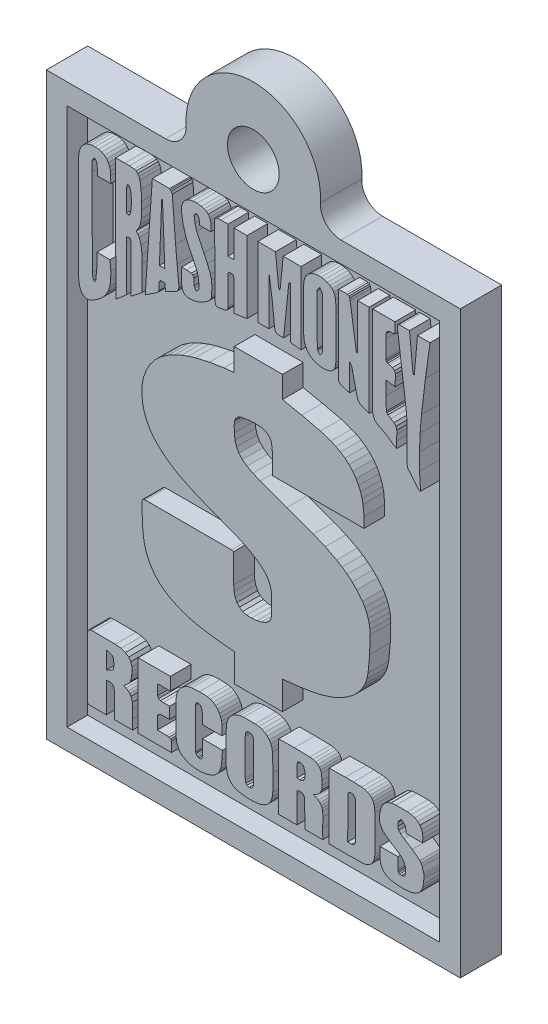
from build123d import *

# Parameters (mm, degrees)
SKETCH3_W           = 63.5
SKETCH3_H           = 88.9
BOSS_EXTRUDE1_DEPTH = 6.35
SKETCH4_W           = 57.15
SKETCH4_H           = 82.55
CUT_EXTRUDE1_DEPTH  = 3.175
BOSS_EXTRUDE2_DEPTH = 3.175
SKETCH6_R           = 3.96875
BOSS_EXTRUDE4_DEPTH = 6.35


with BuildPart() as part:
    # Sketch3 → Boss-Extrude1 (new body)
    with BuildSketch(Plane.XY):
        with Locations((31.75, 44.45)):
            Rectangle(SKETCH3_W, SKETCH3_H)
    extrude(amount=BOSS_EXTRUDE1_DEPTH)

    # Sketch4 → Cut-Extrude1 (cut)
    with BuildSketch(Plane.XY.offset(6.35)):
        with Locations((31.75, 44.45)):
            Rectangle(SKETCH4_W, SKETCH4_H)
    extrude(amount=-CUT_EXTRUDE1_DEPTH, mode=Mode.SUBTRACT)

    # Sketch5 → Boss-Extrude2 (add)
    with BuildSketch(Plane.XY.offset(3.175)):
        Polygon((36.242313877, 26.0782335), (36.218686822, 21.742658016), (28.835213285, 21.74253872), (28.835213285, 26.030896929), (26.804749115, 26.236158537), (24.854026883, 26.467999959), (23.270449094, 26.731960427), (21.718991193, 27.108889057), (20.214052769, 27.640870343), (18.770030909, 28.369989608), (17.985787151, 28.892464651), (17.289453332, 29.475299945), (16.680336685, 30.116834935), (16.157745692, 30.815408642), (15.720988005, 31.569359255), (15.369371261, 32.377026213), (15.102203535, 33.236748123), (14.918792471, 34.146864005), (14.793457399, 35.288723359), (14.731251573, 36.441659517), (14.658893193, 38.754189969), (14.675875085, 39.015935245), (14.768168948, 39.200153774), (14.944634303, 39.309060332), (15.214131496, 39.344870534), (28.409936339, 39.333057006), (28.740717622, 39.262175422), (28.740717622, 34.84388599), (28.794709404, 34.008095871), (28.957792758, 33.307562313), (29.23162825, 32.741316271), (29.617878111, 32.308389124), (30.118202893, 32.007810991), (30.734264413, 31.838613246), (31.467724069, 31.79982727), (32.32024325, 31.890483179), (32.987712161, 32.047013468), (33.619739651, 32.292146046), (34.021217496, 32.544662187), (34.315266419, 32.876920681), (34.491916789, 33.288920699), (34.541200657, 33.780662234), (34.520526773, 34.784820028), (34.553014185, 35.788974472), (34.565243375, 36.457436282), (34.4825018, 37.074259223), (34.311712147, 37.64318133), (34.059796272, 38.167941053), (33.73367644, 38.652276005), (33.340274083, 39.099924228), (32.379311726, 39.900113024), (30.940450278, 40.764352808), (29.427386128, 41.471323903), (26.30712007, 42.68812561), (24.35695373, 43.443089217), (22.427829632, 44.235709017), (20.554076162, 45.143510503), (19.648690797, 45.664831904), (18.770020863, 46.244021672), (18.044637539, 46.788070572), (17.370477423, 47.369082896), (16.754461948, 47.991904692), (16.20351338, 48.661380335), (15.724554415, 49.382355039), (15.3245069, 50.159674433), (15.010293104, 50.998183313), (14.788834461, 51.902727307), (14.647232451, 53.170798267), (14.697093978, 54.405365892), (14.932742916, 55.592863587), (15.34850357, 56.719724339), (15.93869982, 57.772381973), (16.69765513, 58.737269897), (17.619694212, 59.600821512), (18.699140533, 60.349470645), (19.699905213, 60.894280547), (20.724618844, 61.356580356), (21.77065183, 61.745783388), (22.835374146, 62.071303794), (25.010366711, 62.568952092), (27.228555959, 62.924838064), (28.823394732, 63.102042233), (28.823394732, 66.563428401), (36.230520858, 66.563428401), (36.230520858, 63.220177508), (39.185398373, 62.613253451), (42.042808211, 61.944306489), (43.640047198, 61.414724578), (44.397480921, 61.078982971), (45.118781706, 60.684680641), (45.797442954, 60.223372478), (46.426957629, 59.686614629), (47.000818711, 59.065961144), (47.512519173, 58.352968169), (47.901053713, 57.653173428), (48.204169773, 56.936627435), (48.43058958, 56.204299237), (48.58903451, 55.457157459), (48.736888203, 53.922310574), (48.717505679, 52.339839965), (34.659315839, 52.339839965), (34.659315839, 55.600397841), (34.558715837, 56.553792878), (34.424451342, 56.931712738), (34.226642777, 57.246919017), (33.959613606, 57.501765461), (33.617687707, 57.698604567), (33.195188964, 57.839790912), (32.686441674, 57.927677829), (31.995160693, 57.96404141), (31.293912177, 57.926201033), (29.910241778, 57.703219134), (29.441389736, 57.510324848), (29.101010119, 57.178989769), (28.893533734, 56.734686942), (28.823390546, 56.202890253), (28.832135369, 55.074759491), (28.942080459, 54.172979464), (29.172469362, 53.402718382), (29.542544372, 52.740026872), (30.071549882, 52.160953892), (30.778728185, 51.641550065), (31.68332283, 51.157864766), (32.804576949, 50.685948204), (36.886183776, 49.193004142), (40.967765487, 47.708920016), (42.784475636, 46.952478777), (44.523657364, 46.060920369), (45.352408845, 45.545782421), (46.147659081, 44.9744375), (46.904701421, 44.339409956), (47.618829201, 43.633223719), (48.494696656, 42.527175404), (48.847974375, 41.941202335), (49.141307083, 41.332526048), (49.372064767, 40.700591906), (49.537616983, 40.044847783), (49.635333301, 39.364739042), (49.662583696, 38.659712726), (49.593178908, 36.040044373), (49.355429885, 33.438101749), (49.177810473, 32.578108174), (48.898021755, 31.78567381), (48.523539378, 31.057475447), (48.061839414, 30.390191557), (47.520397929, 29.780499344), (46.906689735, 29.22507644), (46.228191743, 28.720600889), (45.49237876, 28.263749906), (44.719740489, 27.862224758), (43.927443006, 27.521337388), (42.293839603, 26.99378565), (40.611505713, 26.625718628), (38.900378498, 26.361760253), align=None)
        Polygon((9.870694513, 79.806407401), (9.882500925, 78.731234913), (7.815112679, 78.731234913), (7.825449409, 79.556710903), (7.791485622, 80.337886376), (7.634955336, 80.643563388), (7.389822757, 80.940379627), (7.177177588, 80.655376078), (7.03541442, 80.361511755), (7.011786948, 78.849370188), (7.059041474, 65.499983627), (7.125493091, 65.02743834), (7.236245643, 64.554893053), (7.567012695, 64.555169326), (7.744216863, 66.504413923), (7.756030389, 68.559981107), (9.764374021, 68.559847158), (9.886434441, 67.13473732), (9.8746544, 65.953633631), (9.732317762, 64.979140678), (9.462707544, 64.17386221), (9.069107198, 63.500402399), (8.554798901, 62.921365837), (7.923066937, 62.399356688), (7.177193912, 61.896979126), (6.505848415, 61.602377661), (6.207208784, 61.573028021), (5.935287938, 61.622312727), (5.691609131, 61.75023219), (5.477695205, 61.95678516), (5.295068585, 62.241972889), (5.14525211, 62.605794963), (5.002012146, 63.209765846), (4.956234412, 63.822598344), (4.956234412, 79.794594711), (4.999935506, 80.385528939), (5.128639416, 80.907104845), (5.338746655, 81.356414461), (5.626657334, 81.730550661), (5.988772384, 82.026606316), (6.421491909, 82.241673882), (6.921216429, 82.37284665), (7.484346884, 82.417217075), (8.013767637, 82.372385362), (8.483520491, 82.240197507), (8.89042079, 82.024114433), (9.231284301, 81.727597487), (9.502928039, 81.354107176), (9.702166938, 80.907104845), (9.825817171, 80.390050999), align=None)
        Polygon((10.671410737, 63.769604488), (10.594066917, 82.50484949), (12.051091109, 82.552967994), (12.769270029, 82.547586564), (13.481449261, 82.464328445), (13.766587177, 82.354913716), (14.005054505, 82.147441516), (14.199517256, 81.8407243), (14.352643125, 81.433575356), (14.545550387, 80.31323335), (14.605111546, 78.776918879), (14.605111546, 77.601811532), (14.577219866, 76.497614235), (14.424649889, 75.621348279), (14.156068993, 74.935025111), (13.780144564, 74.40065617), (14.035099004, 74.129593437), (14.242298699, 73.789676787), (14.52776898, 72.91657623), (14.665226084, 71.807946453), (14.683338179, 70.490379398), (14.676226287, 66.651548054), (13.012072723, 65.336643253), (13.012068537, 68.808909906), (12.990733276, 72.354496025), (12.94739552, 72.777116159), (12.846719753, 72.954712132), (12.700706194, 72.984154277), (12.521356738, 72.96231378), (12.359786175, 72.908496131), (12.295558124, 72.774903478), (12.29378036, 72.253196554), (12.29378036, 65.161856877), align=None)
        Polygon((12.307992425, 79.30388333), (12.300880532, 76.021684206), (12.526678728, 75.921964085), (12.72047508, 75.983695231), (12.876935043, 76.246764934), (12.990724487, 76.751060487), (13.04795157, 77.577942532), (13.027171365, 78.473203393), (12.94371902, 79.246901121), (12.812928428, 79.709092933), (12.636023552, 79.905050062), (12.475119391, 79.893969908), (12.356886163, 79.689149078), align=None, mode=Mode.SUBTRACT)
        Polygon((18.913367148, 68.931172505), (18.288724474, 68.573809739), (18.182401889, 69.672743233), (17.438143795, 69.672466964), (17.33154452, 69.441017347), (17.294165432, 69.194200768), (17.314100919, 68.681601167), (17.272015174, 68.188937052), (17.15710976, 67.967040144), (16.941973126, 67.770477311), (15.169931441, 66.600928878), (16.256782669, 82.596575741), (18.891217726, 82.572948687), (19.02578235, 82.511480836), (19.161454155, 82.373593839), (19.316508065, 82.041335763), (19.824491421, 75.650176352), (20.059286852, 73.104342753), (20.320662091, 70.558496597), (20.317708499, 70.087059326), (20.199572806, 69.702009991), (19.935243558, 69.40556295), align=None)
        Polygon((18.170681289, 71.574552891), (17.816179187, 80.564880909), (17.698089958, 80.564671613), (17.34368162, 71.574511032), align=None, mode=Mode.SUBTRACT)
        Polygon((25.260839696, 81.091125378), (25.223552283, 80.009624185), (23.510578233, 80.009617489), (23.497287911, 80.476255592), (23.439696649, 80.907453112), (23.268399246, 81.146678928), (23.026220256, 81.368185709), (22.791424828, 81.128959893), (22.671811918, 80.907453112), (22.804715149, 79.922493245), (23.061661257, 78.981833895), (24.158851314, 76.679655664), (24.701353513, 75.528013376), (25.176296079, 74.350899294), (25.335410758, 73.674939647), (25.385987657, 72.956894258), (25.365313776, 71.492006381), (25.326735001, 71.269762875), (25.225027404, 71.043088984), (24.916398054, 70.665055267), (24.214410724, 70.156700616), (23.455940147, 69.779034005), (22.642092665, 69.551990498), (21.773975456, 69.495506833), (21.369174817, 69.596660634), (21.051869295, 69.852867924), (20.838670747, 70.246409672), (20.746191865, 70.759565162), (20.722564811, 71.871521497), (20.734378336, 73.063219771), (21.514076178, 73.073556504), (22.258332597, 73.039592717), (22.487221262, 72.877155666), (22.636367989, 72.590676995), (22.671808572, 71.562893404), (22.804711803, 71.274936266), (22.990775908, 70.995838222), (23.271348652, 71.266074236), (23.386161972, 71.399531266), (23.427878938, 71.527451146), (23.364380912, 72.629069495), (23.283346778, 73.168804378), (23.132538655, 73.677528226), (22.73069119, 74.593082469), (22.28343519, 75.490916839), (21.838394803, 76.38875163), (21.443194176, 77.304308801), (21.000183545, 78.806114475), (20.734378336, 80.352221505), (20.724826048, 81.000217056), (20.855098841, 81.551303341), (21.111075488, 82.002712617), (21.478635595, 82.351675062), (21.943658349, 82.595422935), (22.492022523, 82.731186832), (23.109606884, 82.756198171), (23.782291043, 82.667688807), (24.215380602, 82.547175924), (24.569004916, 82.376963513), (24.84676346, 82.151651304), (25.052255713, 81.865840289), (25.189081578, 81.514131456), align=None)
        Polygon((27.868589875, 78.082840022), (28.778238191, 78.082840022), (28.778242798, 82.288478844), (30.786555032, 82.288478844), (30.786555032, 71.254580514), (28.76642592, 70.947426703), (28.76642592, 75.42478796), (28.730984919, 75.873704515), (28.596973672, 76.022851242), (28.305693325, 76.074536159), (28.013121616, 76.00586935), (27.887786963, 75.844170698), (27.868590293, 75.401158392), (27.880403822, 71.396342425), (27.854561572, 71.1026627), (27.753407353, 70.898693288), (27.568081647, 70.763391099), (27.28972326, 70.675713896), (26.462032075, 70.524721175), (26.211546529, 70.524121331), (26.046340908, 70.593018786), (25.948694077, 70.746088147), (25.900886169, 70.998004023), (25.883904277, 71.857075019), (25.813022693, 81.390652843), (25.823175243, 81.937033306), (25.929682008, 82.217606885), (26.220038525, 82.320976299), (26.781738647, 82.335743417), (27.868589875, 82.335743417), align=None)
        Polygon((39.065997273, 82.312102131), (39.065997273, 71.230944667), (37.423905646, 71.408092324), (37.423905646, 79.264159286), (37.211260476, 79.275972815), (36.396122052, 71.490815482), (35.746373853, 71.490815482), (35.409316608, 71.512227762), (35.194087048, 71.644392597), (35.071889327, 71.882880434), (35.013928448, 72.223260887), (34.647706167, 75.689081628), (34.13972239, 79.146033222), (34.13972239, 71.573521059), (32.438561032, 71.573521059), (32.438561032, 82.323906449), (35.155693291, 82.323906449), (35.66367665, 77.574844945), (35.852694345, 77.574844945), (36.337052321, 82.312102131), align=None)
        Polygon((44.403894181, 78.790327664), (44.403895438, 72.221977898), (44.373899909, 71.839673699), (44.285759324, 71.500424701), (44.14224267, 71.20630713), (43.946118107, 70.959398459), (43.700155039, 70.761774076), (43.407122042, 70.615511872), (42.690921387, 70.485378471), (41.97285172, 70.526818325), (41.336601047, 70.675134983), (40.786460365, 70.926451015), (40.326721509, 71.276891092), (39.961676309, 71.722578207), (39.695616177, 72.259636188), (39.53283337, 72.884188447), (39.477618462, 73.592358812), (39.477618462, 80.160708578), (39.521504156, 80.628384374), (39.640425129, 81.053558764), (39.828566292, 81.431386534), (40.080113806, 81.757022472), (40.389252164, 82.025620531), (40.750167526, 82.232335075), (41.157044804, 82.372321318), (41.604070159, 82.440733622), (42.150703449, 82.440156799), (42.652343454, 82.369667437), (43.102760664, 82.232449771), (43.495724754, 82.031687614), (43.825006217, 81.770565206), (44.084374302, 81.4522672), (44.267600348, 81.079976994), (44.36845318, 80.656879244), (44.412754118, 79.728034679), align=None)
        Polygon((42.388196292, 74.519727838), (42.383765904, 76.38037098), (42.36013885, 80.243422108), (42.308453936, 80.427456036), (42.19474821, 80.608167175), (41.923035821, 80.964050634), (41.657229359, 80.597828352), (41.544261612, 80.415824598), (41.497745481, 80.231605229), (41.568627065, 72.647246889), (41.619388565, 72.472072897), (41.744354438, 72.300221274), (42.018439702, 71.999907573), (42.21985206, 72.31058396), (42.348325325, 72.659084695), align=None, mode=Mode.SUBTRACT)
        Polygon((49.528407523, 82.133879107), (49.516593994, 68.004779638), (48.754611005, 68.297179721), (48.098956879, 68.607286285), (47.844964363, 68.887859447), (47.697294012, 69.257034484), (46.882155591, 72.812930547), (46.771403039, 73.099410472), (46.527747253, 73.368168851), (46.527747253, 69.245217609), (45.756908513, 69.4711531), (45.110115581, 69.705950203), (44.893040441, 69.925978935), (44.791148244, 70.225750438), (44.791148244, 81.968493907), (44.873843353, 82.192952605), (45.913439637, 82.192952605), (46.206565981, 82.169878929), (46.406659225, 82.06152617), (46.531440498, 81.862355505), (46.598630094, 81.566829786), (47.543720668, 75.305601597), (47.588021606, 75.183035516), (47.756365838, 75.069329373), (47.756365838, 82.133879107), align=None)
        Polygon((50.053551093, 81.283113828), (50.06536504, 82.169136765), (53.479499191, 82.169138022), (53.479499191, 80.574299248), (53.243226967, 80.503417665), (52.594400926, 80.444349606), (52.261220271, 80.296679258), (52.138469172, 79.945224512), (52.120933478, 79.274801591), (52.109119953, 76.652179227), (52.124809649, 76.411661215), (52.199198624, 76.225412512), (52.346684793, 76.098970261), (52.58166524, 76.037873286), (53.096664213, 75.912722812), (53.41452437, 75.648024365), (53.555180779, 75.250422688), (53.538568503, 74.726564195), (53.514941028, 74.172800594), (53.526754975, 73.557015761), (52.120935992, 73.746033459), (52.112075637, 71.663885628), (52.156376575, 69.634894904), (52.230396348, 69.450307176), (52.40298595, 69.265719449), (52.853379722, 68.985146705), (53.326108352, 68.707157516), (53.622740409, 68.347211196), (53.762104202, 67.898663839), (53.763028038, 67.354869863), (53.734970596, 66.454082319), (53.751214509, 65.4646929), (53.219601585, 65.760033183), (52.278942234, 66.42011895), (51.799198825, 66.725242163), (51.293982367, 66.965019685), (50.91986877, 67.138970551), (50.624667044, 67.342132919), (50.399792684, 67.574921194), (50.236663281, 67.837751461), (50.061304689, 68.455197688), (50.029924039, 69.197793967), (50.063888244, 75.240449292), align=None)
        Polygon((54.305524794, 82.127336499), (55.711343777, 82.115522973), (56.254769812, 76.598588042), (56.443787506, 76.586774513), (56.939958176, 82.080094111), (58.865577393, 82.080094111), (58.155100161, 76.975877498), (57.549837079, 71.876087509), (57.345844224, 69.322314042), (57.239175462, 66.763001752), (57.253504316, 64.195935032), (57.412503463, 61.618898683), (57.188044765, 61.618898683), (55.486883407, 63.639027796), (55.377607648, 63.937321667), (55.356933768, 64.288775995), (55.334783088, 65.913146495), (55.356933768, 67.537516992), (55.36265593, 69.161702892), (55.260948333, 70.775920839), (54.872575791, 73.987739855), (53.844792197, 81.572098195), (53.838700833, 81.819999347), (53.902383877, 81.995911739), (54.052454019, 82.098726936), align=None)
        Polygon((51.198253531, 9.834410886), (51.174626474, 11.334739767), (53.939017869, 11.334729721), (53.939017869, 9.739890948), (53.957107359, 9.488851604), (54.030573334, 9.282113615), (54.188211635, 9.141827243), (54.458818101, 9.090142746), (54.736437674, 9.12835232), (54.925455368, 9.254056593), (55.043591482, 9.457288028), (55.108566303, 9.728078255), (55.118349655, 10.456276616), (54.912165047, 11.061539279), (54.508840786, 11.56712452), (53.927205177, 11.99629061), (52.813772463, 12.681480649), (51.788940789, 13.472994108), (51.485270512, 13.811435638), (51.275601956, 14.1759036), (51.148721019, 14.560307046), (51.093414439, 14.95855503), (51.152667095, 15.772217912), (51.36365045, 16.568161759), (51.509105606, 16.91310948), (51.703291249, 17.212371976), (52.22013622, 17.672732861), (52.878744356, 17.947030062), (53.643675494, 18.033048379), (55.368462232, 18.033048379), (55.990799716, 17.966181522), (56.5261963, 17.803790098), (56.970776235, 17.550028225), (57.320662098, 17.209048346), (57.57197813, 16.785004579), (57.720847748, 16.282049776), (57.763394782, 15.704337222), (57.695742223, 15.056020192), (55.167629755, 15.056020192), (55.160246193, 15.52856464), (55.073120695, 15.965668508), (54.799930674, 16.272822734), (54.446997876, 16.54453638), (54.150180383, 16.246242923), (54.020046143, 16.092666648), (53.950827209, 15.930230436), (53.918708999, 15.348409811), (54.04828944, 14.917212705), (54.359504016, 14.561327993), (54.872288215, 14.205443698), (56.12305413, 13.419839512), (57.294078102, 12.527911905), (57.511152821, 12.248446341), (57.66620631, 11.89588358), (57.896571354, 11.122092923), (57.929058763, 10.752918304), (57.908384882, 10.366022139), (57.871213419, 9.712627576), (57.757207143, 9.150327191), (57.562628439, 8.676075302), (57.283739277, 8.286825807), (56.916801617, 7.979533443), (56.45807785, 7.751152532), (55.903829935, 7.598637388), (55.250320261, 7.518941913), (54.117690878, 7.521895087), (52.993920596, 7.648891552), (52.591150552, 7.749584064), (52.234896641, 7.907314037), (51.92737405, 8.11820572), (51.670797144, 8.37838211), (51.467381945, 8.683967033), (51.319342816, 9.031084319), (51.228894946, 9.415857799), align=None)
        Polygon((43.377518317, 7.755212044), (43.377518317, 17.83220711), (45.883468807, 17.86322233), (47.127040363, 17.857130966), (48.362862931, 17.796770713), (48.870755454, 17.721413117), (49.298353076, 17.583756345), (49.649531131, 17.383524965), (49.928166209, 17.120441032), (50.138134895, 16.794228689), (50.283313364, 16.404609996), (50.36757778, 15.951309098), (50.394804733, 15.434048466), (50.394804733, 9.834406283), (50.362594011, 9.41562255), (50.267808265, 9.031449332), (50.113216063, 8.687701298), (49.90158598, 8.390192707), (49.635687428, 8.144737393), (49.31828856, 7.957150865), (48.952158368, 7.833246544), (48.540065843, 7.778839098), (45.98094234, 7.740444926), align=None)
        Polygon((46.248211366, 15.882942839), (46.236397838, 9.444524295), (46.825418677, 9.430687707), (47.200685917, 9.564144737), (47.400963341, 9.868160355), (47.465014744, 10.365992837), (47.465014744, 15.268636059), (47.430312143, 15.634489142), (47.311437633, 15.936104967), (47.086240117, 16.149118499), (46.732569343, 16.249164702), (46.432799094, 16.119215063), align=None, mode=Mode.SUBTRACT)
        Polygon((35.628088304, 7.814261682), (35.628088304, 17.843997615), (38.04840851, 17.872073474), (40.424416895, 17.820388978), (40.898069359, 17.756590405), (41.29419508, 17.635616232), (41.617223603, 17.45677369), (41.871585735, 17.219370848), (42.061710609, 16.922715349), (42.192029449, 16.566115258), (42.290968475, 15.670311901), (42.290968475, 14.985121444), (42.244636943, 14.341279172), (41.991197808, 13.830340128), (41.545048567, 13.43015406), (40.920587562, 13.118569864), (41.344100555, 12.960516317), (41.688287274, 12.762315532), (41.959100526, 12.525904753), (42.1624927, 12.253222904), (42.304417863, 11.946207648), (42.390827985, 11.606797495), (42.42091644, 10.83854482), (42.392858998, 9.354459856), (42.409102911, 7.826074371), (39.644719893, 7.826074371), (39.644719893, 9.858016177), (39.609278892, 11.925396048), (39.537289711, 12.208737365), (39.370053076, 12.393509275), (39.12750447, 12.491894921), (38.82957854, 12.516076613), (38.561188523, 12.447779002), (38.454496737, 12.28866474), (38.451543148, 11.866328411), (38.451543148, 7.814261682), align=None)
        Polygon((38.475174388, 15.977466966), (38.46336086, 14.063660438), (38.83844643, 14.005517052), (39.160367356, 14.041511852), (39.420266637, 14.194903948), (39.609282657, 14.488952453), (39.704345515, 14.971096491), (39.669827511, 15.493110661), (39.531202115, 15.944242414), (39.313942378, 16.21373919), (39.020078891, 16.327999132), (38.752796054, 16.321538571), (38.55639438, 16.202110262), align=None, mode=Mode.SUBTRACT)
        Polygon((27.583072714, 10.33057737), (27.59488624, 12.870502529), (27.583067272, 14.181816223), (27.606694326, 15.493127406), (27.683113892, 16.031569673), (27.845920142, 16.517958662), (28.088468748, 16.946755971), (28.40411413, 17.312424039), (28.78621113, 17.609425715), (29.228114163, 17.832222599), (29.723178492, 17.975277544), (30.264758948, 18.033052568), (32.060426015, 18.033052568), (32.580132903, 17.975046063), (33.061630217, 17.839235284), (33.496610979, 17.62977477), (33.876769056, 17.350816539), (34.193798308, 17.006514289), (34.439392178, 16.601021298), (34.605244106, 16.138490427), (34.683048379, 15.623075371), (34.777557438, 12.935479025), (34.730302908, 10.247882676), (34.670888676, 9.707894966), (34.545161382, 9.230620833), (34.352151985, 8.815644623), (34.090891021, 8.462551505), (33.76040987, 8.170926235), (33.35973949, 7.940353152), (32.88791125, 7.77041701), (32.343955279, 7.66070257), (31.617233297, 7.592959175), (30.88054378, 7.597204544), (29.425994726, 7.790652209), (29.016832771, 7.913356842), (28.657924977, 8.101128807), (28.349686595, 8.349261022), (28.092533284, 8.653045995), (27.886879872, 9.007777486), (27.73314202, 9.408747999), align=None)
        Polygon((31.776899679, 10.011607941), (31.776899679, 15.587637302), (31.763978556, 15.906973837), (31.691251396, 16.184224208), (31.507771684, 16.381732641), (31.162593738, 16.46184336), (30.816860737, 16.398898716), (30.620644081, 16.215233985), (30.532965203, 15.945181736), (30.512845539, 15.623075371), (30.512845539, 10.035237506), (30.529089035, 9.709072047), (30.607354178, 9.428313867), (30.791941487, 9.229511981), (31.12715148, 9.149214572), (31.467901134, 9.21418939), (31.664671167, 9.403207088), (31.755118619, 9.680827075), align=None, mode=Mode.SUBTRACT)
        Polygon((26.944896931, 15.363166464), (26.933083406, 13.886467151), (23.932427739, 13.886471758), (23.94719486, 14.843374601), (23.908800685, 15.764836028), (23.737503279, 16.156161741), (23.586510558, 16.321367784), (23.424442708, 16.414584227), (23.170080574, 16.415138026), (23.002105961, 16.286111384), (22.909443317, 16.070697641), (22.881017094, 15.812090975), (22.904644149, 9.728095001), (22.952267877, 9.559566586), (23.072987963, 9.381069804), (23.233579017, 9.231368861), (23.400814815, 9.149227129), (23.660160298, 9.151995702), (23.827581115, 9.277699972), (23.917475185, 9.489790925), (23.944240429, 9.75172038), (23.944240429, 12.008120045), (27.015778515, 12.008120045), (26.92717664, 10.698286076), (26.859617428, 10.056105197), (26.732251761, 9.432752626), (26.595610497, 9.057554876), (26.409961217, 8.72818132), (25.908251311, 8.199707006), (25.260348267, 7.832931341), (24.499477479, 7.613455993), (23.759466011, 7.51359397), (23.027206461, 7.505656612), (22.301592074, 7.601827065), (21.581516926, 7.814287216), (20.849257379, 8.22148723), (20.563769517, 8.481709244), (20.330750597, 8.777095989), (20.018243822, 9.465607979), (19.903985136, 10.271519358), (19.903985136, 15.245030351), (19.956615654, 15.750870094), (20.092449453, 16.226114468), (20.304979091, 16.662317942), (20.587697958, 17.051036662), (20.934099872, 17.383825098), (21.337677381, 17.652238975), (21.791923882, 17.84783318), (22.290332765, 17.96216261), (23.495321361, 18.043381344), (24.700309959, 17.973976138), (25.151442127, 17.869061281), (25.56934849, 17.677344079), (25.946276284, 17.410591599), (26.274473174, 17.080572154), (26.546186402, 16.699052395), (26.753663205, 16.277799803), (26.889150827, 15.828582277), align=None)
        Polygon((17.9309833, 13.806745723), (18.923327565, 13.827419606), (18.923311241, 12.055366618), (18.205634211, 12.065703351), (17.505679565, 12.031739564), (17.213292875, 11.885546008), (17.044946968, 11.641890226), (17.021319913, 9.704458319), (18.521648791, 9.704458319), (18.847998433, 9.676954675), (19.068026744, 9.555311171), (19.186163693, 9.333990665), (19.206839248, 9.007455172), (19.206839248, 7.802468666), (14.079746537, 7.802468666), (14.079746537, 17.844050777), (19.029648893, 17.844050777), (19.029648893, 15.882989302), (17.151284623, 15.882989302), (17.044962038, 15.682158079), (17.031671714, 14.742975942), (17.069881288, 14.309932846), (17.222166207, 13.980996721), (17.507907735, 13.837387141), align=None)
        Polygon((9.815211704, 12.452974574), (9.200904924, 12.4452214), (9.200906181, 7.814280102), (6.365638644, 7.814280102), (6.318384118, 8.487657866), (6.306570589, 17.052528107), (6.346810758, 17.477818447), (6.495588286, 17.743624491), (6.76840827, 17.876527304), (7.180776647, 17.903108786), (10.571282488, 17.879481732), (11.454326298, 17.790741304), (12.131232384, 17.561621993), (12.620689658, 17.207906007), (12.941388296, 16.745375556), (13.112016789, 16.189812842), (13.15126531, 15.557000069), (13.077822775, 14.862719451), (12.910379355, 14.122753189), (12.745727111, 13.823351302), (12.470322316, 13.552745675), (11.835340816, 13.035901961), (12.223782428, 12.886870348), (12.541757278, 12.689800179), (12.794111424, 12.447598169), (12.985690488, 12.16317186), (13.205903399, 11.479275273), (13.241159799, 10.661367022), (13.217532327, 9.249640855), (13.229346274, 7.802474109), (10.453146374, 7.802474109), (10.453146374, 11.452880063), (10.397031493, 11.990029299), (10.199153859, 12.312319004), align=None)
        Polygon((9.259977165, 16.438209606), (9.259977165, 13.803774553), (9.936303499, 14.119792483), (10.186973646, 14.258971257), (10.311387395, 14.418084682), (10.377839009, 15.209595628), (10.240505811, 16.001106577), (10.11886231, 16.130871619), (9.878713915, 16.232948834), align=None, mode=Mode.SUBTRACT)
    extrude(amount=BOSS_EXTRUDE2_DEPTH)

    # Sketch6 → Boss-Extrude4 (add)
    with BuildSketch(Plane.XY):
        with BuildLine():
            Line((18.279615818, 88.9), (31.75, 86.36))
            Line((31.75, 86.36), (45.220384182, 88.9))
            ThreePointArc((45.220384182, 88.9), (42.910232353, 89.896967969), (42.050882021, 92.261764706))
            ThreePointArc((42.050882021, 92.261764706), (31.75, 103.1875), (21.449117979, 92.261764706))
            ThreePointArc((21.449117979, 92.261764706), (20.589767647, 89.896967969), (18.279615818, 88.9))
        make_face()
        with Locations((31.75, 92.86875)):
            Circle(SKETCH6_R, mode=Mode.SUBTRACT)
    extrude(amount=BOSS_EXTRUDE4_DEPTH)


solid = part.part
